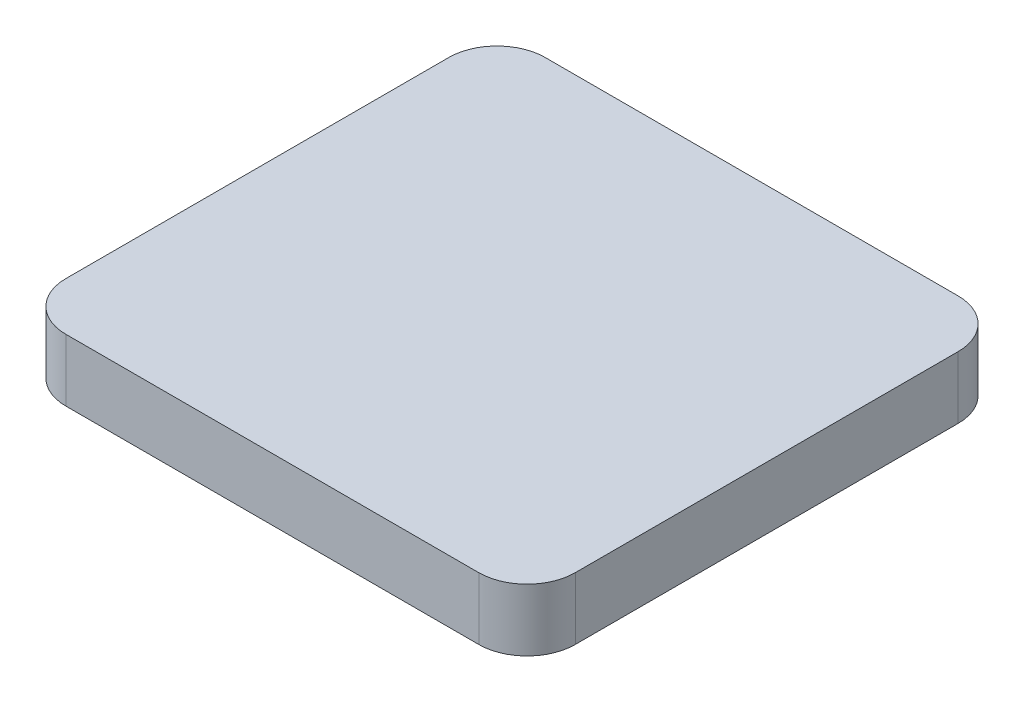
from build123d import *

# Parameters (mm, degrees)
BOSS_EXTRUDE1_DEPTH = 1.3
BOSS_EXTRUDE2_DEPTH = 1.5
SKETCH3_R           = 0.4
BOSS_EXTRUDE3_DEPTH = 1.3
BOSS_EXTRUDE4_DEPTH = 3
CUT_EXTRUDE1_DEPTH  = 0.5
SKETCH8_R           = 0.4
BOSS_EXTRUDE5_DEPTH = 3


with BuildPart() as part:
    # Sketch1 → Boss-Extrude1 (new body)
    with BuildSketch(Plane(origin=(0, 0, 0), x_dir=(1, 0, 0), z_dir=(0, 1, 0))):
        with BuildLine():
            Line((-19.250000047, -22.35), (19.25, -22.35))
            ThreePointArc((19.25, -22.35), (22.431980515, -21.031980515), (23.75, -17.85))
            Line((23.75, -17.85), (23.75, 17.85))
            ThreePointArc((23.75, 17.85), (22.431980515, 21.031980515), (19.25, 22.35))
            Line((19.25, 22.35), (-19.249999992, 22.35))
            ThreePointArc((-19.249999992, 22.35), (-22.431980512, 21.031980518), (-23.75, 17.85))
            Line((-23.75, 17.85), (-23.75, -17.85))
            ThreePointArc((-23.75, -17.85), (-22.431980532, -21.031980499), (-19.250000047, -22.35))
        make_face()
        with BuildLine():
            ThreePointArc((19.25, 20.35), (21.017766953, 19.617766953), (21.75, 17.85))
            Line((21.75, 17.85), (21.75, -17.85))
            ThreePointArc((21.75, -17.85), (21.017766953, -19.617766953), (19.25, -20.35))
            Line((19.25, -20.35), (-19.25, -20.35))
            ThreePointArc((-19.25, -20.35), (-21.017766953, -19.617766953), (-21.75, -17.85))
            Line((-21.75, -17.85), (-21.75, 17.85))
            ThreePointArc((-21.75, 17.85), (-21.017766953, 19.617766953), (-19.25, 20.35))
            Line((-19.25, 20.35), (19.25, 20.35))
        make_face(mode=Mode.SUBTRACT)
    extrude(amount=BOSS_EXTRUDE1_DEPTH)

    # Sketch2 → Boss-Extrude2 (add)
    with BuildSketch(Plane(origin=(0, 1.3, 0), x_dir=(1, 0, 0), z_dir=(0, 1, 0))):
        with BuildLine():
            Line((-19.25, -22.35), (19.25, -22.35))
            ThreePointArc((19.25, -22.35), (22.431980515, -21.031980515), (23.75, -17.85))
            Line((23.75, -17.85), (23.75, 17.85))
            ThreePointArc((23.75, 17.85), (22.431980515, 21.031980515), (19.25, 22.35))
            Line((19.25, 22.35), (-19.25, 22.35))
            ThreePointArc((-19.25, 22.35), (-22.431980515, 21.031980515), (-23.75, 17.85))
            Line((-23.75, 17.85), (-23.75, -17.85))
            ThreePointArc((-23.75, -17.85), (-22.431980515, -21.031980515), (-19.25, -22.35))
        make_face()
    extrude(amount=BOSS_EXTRUDE2_DEPTH)

    # Sketch3 → Boss-Extrude3 (add)
    with BuildSketch(Plane.XZ.offset(-1.3)):
        with Locations((-21.75, 11.175)):
            Circle(SKETCH3_R)
        with Locations((-21.75, 0)):
            Circle(SKETCH3_R)
        with Locations((-21.75, -11.175)):
            Circle(SKETCH3_R)
        with Locations((-11.175, -20.35)):
            Circle(SKETCH3_R)
        with Locations((11.175, -20.35)):
            Circle(SKETCH3_R)
        with Locations((21.75, -11.175)):
            Circle(SKETCH3_R)
        with Locations((21.75, 0)):
            Circle(SKETCH3_R)
        with Locations((21.75, 11.175)):
            Circle(SKETCH3_R)
        with Locations((11.175, 20.35)):
            Circle(SKETCH3_R)
        with Locations((0, 20.35)):
            Circle(SKETCH3_R)
        with Locations((-11.175, 20.35)):
            Circle(SKETCH3_R)
        with Locations((0, -20.35)):
            Circle(SKETCH3_R)
    extrude(amount=BOSS_EXTRUDE3_DEPTH)

    # Sketch4 → Boss-Extrude4 (add)
    with BuildSketch(Plane.XZ):
        with BuildLine():
            Line((19.25, 22.35), (-19.25, 22.35))
            ThreePointArc((-19.25, 22.35), (-22.431980515, 21.031980515), (-23.75, 17.85))
            Line((-23.75, 17.85), (-23.75, -17.85))
            ThreePointArc((-23.75, -17.85), (-22.431980515, -21.031980515), (-19.25, -22.35))
            Line((-19.25, -22.35), (19.25, -22.35))
            ThreePointArc((19.25, -22.35), (22.431980515, -21.031980515), (23.75, -17.85))
            Line((23.75, -17.85), (23.75, 17.85))
            ThreePointArc((23.75, 17.85), (22.431980515, 21.031980515), (19.25, 22.35))
        make_face()
        with BuildLine():
            Line((-22.75, 17.85), (-22.75, -17.85))
            ThreePointArc((-22.75, -17.85), (-21.724873734, -20.324873734), (-19.25, -21.35))
            Line((-19.25, -21.35), (19.25, -21.35))
            ThreePointArc((19.25, -21.35), (21.724873734, -20.324873734), (22.75, -17.85))
            Line((22.75, -17.85), (22.75, 17.85))
            ThreePointArc((22.75, 17.85), (21.724873734, 20.324873734), (19.25, 21.35))
            Line((19.25, 21.35), (-19.25, 21.35))
            ThreePointArc((-19.25, 21.35), (-21.724873734, 20.324873734), (-22.75, 17.85))
        make_face(mode=Mode.SUBTRACT)
    extrude(amount=BOSS_EXTRUDE4_DEPTH)

    # Sketch5 → Cut-Extrude1 (cut)
    with BuildSketch(Plane.XZ.offset(-1.3)):
        with BuildLine():
            Line((0.979795897, -19.35), (10.195204103, -19.35))
            ThreePointArc((10.195204103, -19.35), (11.175, -18.95), (12.154795897, -19.35))
            Line((12.154795897, -19.35), (19.25, -19.35))
            ThreePointArc((19.25, -19.35), (20.310660172, -18.910660172), (20.75, -17.85))
            Line((20.75, -17.85), (20.75, -12.154795897))
            ThreePointArc((20.75, -12.154795897), (20.35, -11.175), (20.75, -10.195204103))
            Line((20.75, -10.195204103), (20.75, -0.979795897))
            ThreePointArc((20.75, -0.979795897), (20.35, 0), (20.75, 0.979795897))
            Line((20.75, 0.979795897), (20.75, 10.195204103))
            ThreePointArc((20.75, 10.195204103), (20.35, 11.175), (20.75, 12.154795897))
            Line((20.75, 12.154795897), (20.75, 17.85))
            ThreePointArc((20.75, 17.85), (20.310660172, 18.910660172), (19.25, 19.35))
            Line((19.25, 19.35), (12.154795897, 19.35))
            ThreePointArc((12.154795897, 19.35), (11.175, 18.95), (10.195204103, 19.35))
            Line((10.195204103, 19.35), (0.979795897, 19.35))
            ThreePointArc((0.979795897, 19.35), (0, 18.95), (-0.979795897, 19.35))
            Line((-0.979795897, 19.35), (-10.195204103, 19.35))
            ThreePointArc((-10.195204103, 19.35), (-11.175, 18.95), (-12.154795897, 19.35))
            Line((-12.154795897, 19.35), (-19.25, 19.35))
            ThreePointArc((-19.25, 19.35), (-20.310660172, 18.910660172), (-20.75, 17.85))
            Line((-20.75, 17.85), (-20.75, 12.154795897))
            ThreePointArc((-20.75, 12.154795897), (-20.35, 11.175), (-20.75, 10.195204103))
            Line((-20.75, 10.195204103), (-20.75, 0.979795897))
            ThreePointArc((-20.75, 0.979795897), (-20.35, 0), (-20.75, -0.979795897))
            Line((-20.75, -0.979795897), (-20.75, -10.195204103))
            ThreePointArc((-20.75, -10.195204103), (-20.35, -11.175), (-20.75, -12.154795897))
            Line((-20.75, -12.154795897), (-20.75, -17.85))
            ThreePointArc((-20.75, -17.85), (-20.310660172, -18.910660172), (-19.25, -19.35))
            Line((-19.25, -19.35), (-12.154795897, -19.35))
            ThreePointArc((-12.154795897, -19.35), (-11.175, -18.95), (-10.195204103, -19.35))
            Line((-10.195204103, -19.35), (-0.979795897, -19.35))
            ThreePointArc((-0.979795897, -19.35), (0, -18.95), (0.979795897, -19.35))
        make_face()
    extrude(amount=-CUT_EXTRUDE1_DEPTH, mode=Mode.SUBTRACT)

    # Sketch8 → Boss-Extrude5 (add)
    with BuildSketch(Plane.XZ):
        with Locations((-11.175, 21.35)):
            Circle(SKETCH8_R)
        with Locations((0, 21.35)):
            Circle(SKETCH8_R)
        with Locations((11.175, 21.35)):
            Circle(SKETCH8_R)
        with Locations((22.75, 11.175)):
            Circle(SKETCH8_R)
        with Locations((-22.75, 11.175)):
            Circle(SKETCH8_R)
        with Locations((-22.75, 0)):
            Circle(SKETCH8_R)
        with Locations((22.75, 0)):
            Circle(SKETCH8_R)
        with Locations((22.75, -11.175)):
            Circle(SKETCH8_R)
        with Locations((11.175, -21.35)):
            Circle(SKETCH8_R)
        with Locations((0, -21.35)):
            Circle(SKETCH8_R)
        with Locations((-11.175, -21.35)):
            Circle(SKETCH8_R)
        with Locations((-22.75, -11.175)):
            Circle(SKETCH8_R)
    extrude(amount=BOSS_EXTRUDE5_DEPTH)


solid = part.part
